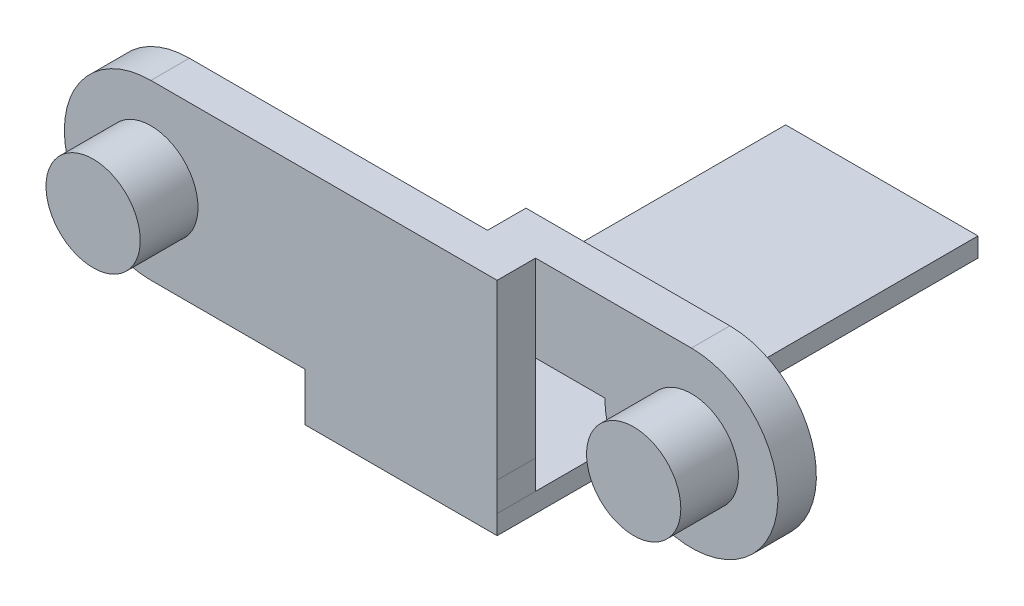
from build123d import *

# Parameters (mm, degrees)
SKETCH_1_R       = 2.45
EXTRUDE_2_DEPTH  = 2
SKETCH_1_5_R     = 2.45
EXTRUDE_3_DEPTH  = 2
SKETCH_8_R       = 2.45
EXTRUDE_5_DEPTH  = 3
SKETCH_10_R      = 2.529452546
EXTRUDE_6_DEPTH  = 2
SKETCH_11_W      = 2.5
SKETCH_11_H      = 4.5
EXTRUDE_7_DEPTH  = 2
SKETCH_1_7_W     = 10
SKETCH_1_7_H     = 1
EXTRUDE_8_DEPTH  = 23
SKETCH_13_W      = 10
SKETCH_13_H      = 1
EXTRUDE_9_DEPTH  = 2
SKETCH_21_R      = 2.45
EXTRUDE_10_DEPTH = 5


with BuildPart() as part:
    # 草图1 → 凸台-拉伸2 (new body)
    with BuildSketch(Plane.XY):
        with BuildLine():
            Line((-52.360741066, -3.31033927), (-60.460741066, -3.31033927))
            Line((-60.460741066, -3.31033927), (-60.460741066, -7.81033927))
            Line((-60.460741066, -7.81033927), (-56.860741066, -7.81033927))
            ThreePointArc((-56.860741066, -7.81033927), (-49.178760551, -10.992319786), (-52.360741066, -3.31033927))
        make_face()
        with Locations((-52.360741066, -7.81033927)):
            Circle(SKETCH_1_R, mode=Mode.SUBTRACT)
    extrude(amount=-EXTRUDE_2_DEPTH)



with BuildPart() as body_2:
    # 草图1<5> → 凸台-拉伸3 (new body)
    with BuildSketch(Plane.XY):
        with BuildLine():
            Line((-78.460741066, -12.31033927), (-70.458584645, -12.31033927))
            Line((-70.458584645, -12.31033927), (-70.458584645, -13.81033927))
            Line((-70.458584645, -13.81033927), (-60.458584645, -13.81033927))
            Line((-60.458584645, -13.81033927), (-60.460741066, -12.31033927))
            Line((-60.460741066, -12.31033927), (-60.460741066, -7.81033927))
            Line((-60.460741066, -7.81033927), (-60.460741066, -3.31033927))
            Line((-60.460741066, -3.31033927), (-78.460741066, -3.31033927))
            ThreePointArc((-78.460741066, -3.31033927), (-82.960741066, -7.81033927), (-78.460741066, -12.31033927))
        make_face()
        with Locations((-78.460741066, -7.81033927)):
            Circle(SKETCH_1_5_R, mode=Mode.SUBTRACT)
    extrude(amount=EXTRUDE_3_DEPTH)


with BuildPart() as body_3:
    # 草图8 → 凸台-拉伸5 (new body)
    with BuildSketch(Plane.XY):
        with Locations((-52.360741066, -7.81033927)):
            Circle(SKETCH_8_R)
    extrude(amount=EXTRUDE_5_DEPTH)


with BuildPart() as part_1:
    add(part.part)

    add(body_3.part)  # 凸台-拉伸6 merges body 3
    # 草图10 → 凸台-拉伸6 (add)
    with BuildSketch(Plane.XY):
        with Locations((-52.43882399, -7.795650359)):
            Circle(SKETCH_10_R)
    extrude(amount=-EXTRUDE_6_DEPTH)


    add(body_2.part)  # 凸台-拉伸7 merges body 2
    # 草图11 → 凸台-拉伸7 (add)
    with BuildSketch(Plane(origin=(0, 0, 0), x_dir=(-1, 0, 0), z_dir=(0, 0, -1))):
        with Locations((61.710741066, -5.56033927)):
            Rectangle(SKETCH_11_W, SKETCH_11_H)
    extrude(amount=EXTRUDE_7_DEPTH)



with BuildPart() as body_2_2:
    # 草图1<7> → 凸台-拉伸8 (new body)
    with BuildSketch(Plane.XY):
        with Locations((-65.458584645, -14.31033927)):
            Rectangle(SKETCH_1_7_W, SKETCH_1_7_H)
    extrude(amount=-EXTRUDE_8_DEPTH)


with BuildPart() as part_2:
    add(part_1.part)

    add(body_2_2.part)  # 凸台-拉伸9 merges body 2 2
    # 草图13 → 凸台-拉伸9 (add)
    with BuildSketch(Plane.XY):
        with Locations((-65.458584645, -14.31033927)):
            Rectangle(SKETCH_13_W, SKETCH_13_H)
    extrude(amount=EXTRUDE_9_DEPTH)

    # 草图21 → 凸台-拉伸10 (add)
    with BuildSketch(Plane(origin=(0, 0, 0), x_dir=(-1, 0, 0), z_dir=(0, 0, -1))):
        with Locations((78.465233983, -7.801636169)):
            Circle(SKETCH_21_R)
    extrude(amount=-EXTRUDE_10_DEPTH)


solid = part_2.part
